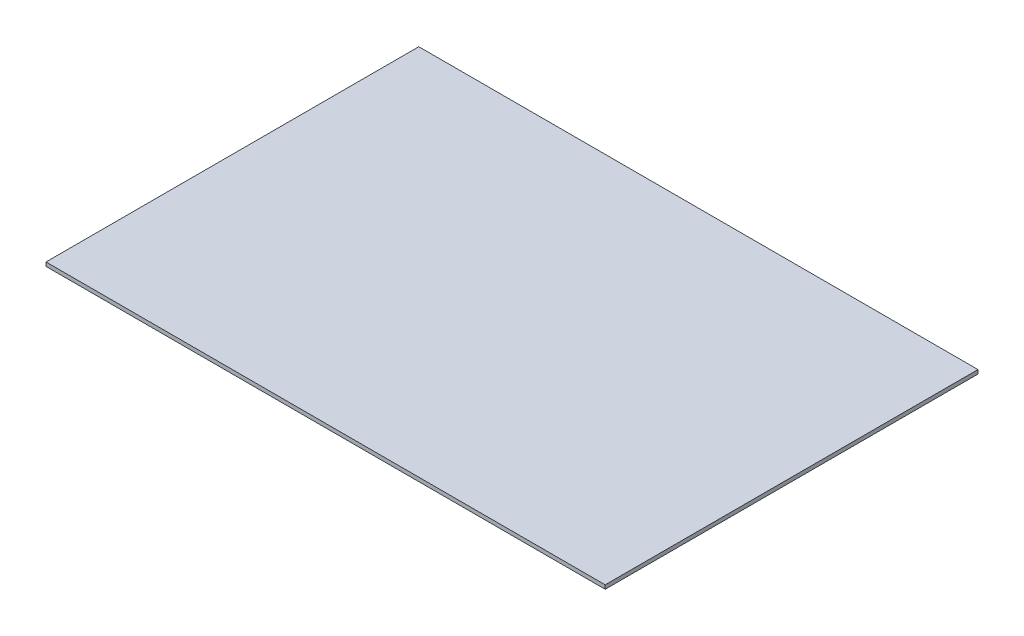
from build123d import *

# Parameters (mm, degrees)
SKETCH1_W           = 457.2
SKETCH1_H           = 304.8
BOSS_EXTRUDE1_DEPTH = 3.175


with BuildPart() as part:
    # Sketch1 → Boss-Extrude1 (new body)
    with BuildSketch(Plane(origin=(0, 0, 0), x_dir=(1, 0, 0), z_dir=(0, 1, 0))):
        Rectangle(SKETCH1_W, SKETCH1_H)
    extrude(amount=BOSS_EXTRUDE1_DEPTH)


solid = part.part
